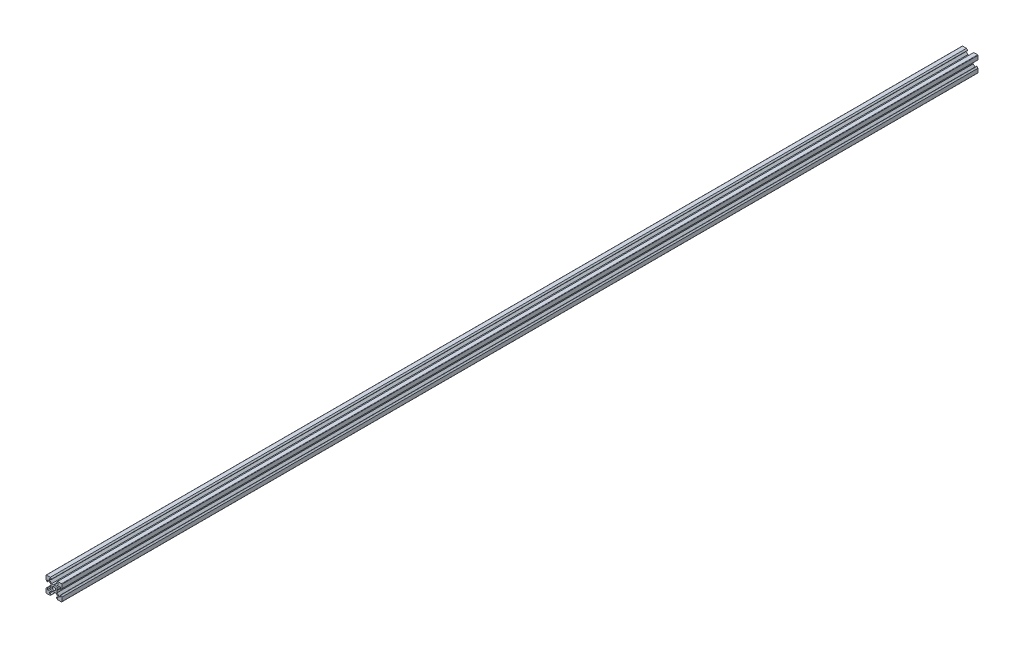
from build123d import *

# Parameters (mm, degrees)
SKETCH1_R           = 2.1
BOSS_EXTRUDE1_DEPTH = 1160


with BuildPart() as part:
    # Sketch1 → Boss-Extrude1 (new body)
    with BuildSketch(Plane.XY):
        with BuildLine():
            Line((4.58, -10), (9.5, -10))
            ThreePointArc((9.5, -10), (9.853553391, -9.853553391), (10, -9.5))
            Line((10, -9.5), (10, -4.58))
            Line((10, -4.58), (8.545, -3.125))
            Line((8.545, -3.125), (8.2, -3.125))
            Line((8.2, -3.125), (8.2, -5.5))
            Line((8.2, -5.5), (6.560660172, -5.5))
            Line((6.560660172, -5.5), (3.9, -2.839339828))
            Line((3.9, -2.839339828), (3.9, -0.21))
            Line((3.9, -0.21), (3.69, 0))
            Line((3.69, 0), (3.9, 0.21))
            Line((3.9, 0.21), (3.9, 2.839339828))
            Line((3.9, 2.839339828), (6.560660172, 5.5))
            Line((6.560660172, 5.5), (8.2, 5.5))
            Line((8.2, 5.5), (8.2, 3.125))
            Line((8.2, 3.125), (8.545, 3.125))
            Line((8.545, 3.125), (10, 4.58))
            Line((10, 4.58), (10, 9.5))
            ThreePointArc((10, 9.5), (9.853553391, 9.853553391), (9.5, 10))
            Line((9.5, 10), (4.58, 10))
            Line((4.58, 10), (3.125, 8.545))
            Line((3.125, 8.545), (3.125, 8.2))
            Line((3.125, 8.2), (5.5, 8.2))
            Line((5.5, 8.2), (5.5, 6.560660172))
            Line((5.5, 6.560660172), (2.839339828, 3.9))
            Line((2.839339828, 3.9), (0.21, 3.9))
            Line((0.21, 3.9), (0, 3.69))
            Line((0, 3.69), (-0.21, 3.9))
            Line((-0.21, 3.9), (-2.839339828, 3.9))
            Line((-2.839339828, 3.9), (-5.5, 6.560660172))
            Line((-5.5, 6.560660172), (-5.5, 8.2))
            Line((-5.5, 8.2), (-3.125, 8.2))
            Line((-3.125, 8.2), (-3.125, 8.545))
            Line((-3.125, 8.545), (-4.58, 10))
            Line((-4.58, 10), (-9.5, 10))
            ThreePointArc((-9.5, 10), (-9.853553391, 9.853553391), (-10, 9.5))
            Line((-10, 9.5), (-10, 4.58))
            Line((-10, 4.58), (-8.545, 3.125))
            Line((-8.545, 3.125), (-8.2, 3.125))
            Line((-8.2, 3.125), (-8.2, 5.5))
            Line((-8.2, 5.5), (-6.560660172, 5.5))
            Line((-6.560660172, 5.5), (-3.9, 2.839339828))
            Line((-3.9, 2.839339828), (-3.9, 0.21))
            Line((-3.9, 0.21), (-3.69, 0))
            Line((-3.69, 0), (-3.9, -0.21))
            Line((-3.9, -0.21), (-3.9, -2.839339828))
            Line((-3.9, -2.839339828), (-6.560660172, -5.5))
            Line((-6.560660172, -5.5), (-8.2, -5.5))
            Line((-8.2, -5.5), (-8.2, -3.125))
            Line((-8.2, -3.125), (-8.545, -3.125))
            Line((-8.545, -3.125), (-10, -4.58))
            Line((-10, -4.58), (-10, -9.5))
            ThreePointArc((-10, -9.5), (-9.853553391, -9.853553391), (-9.5, -10))
            Line((-9.5, -10), (-4.58, -10))
            Line((-4.58, -10), (-3.125, -8.545))
            Line((-3.125, -8.545), (-3.125, -8.2))
            Line((-3.125, -8.2), (-5.5, -8.2))
            Line((-5.5, -8.2), (-5.5, -6.560660172))
            Line((-5.5, -6.560660172), (-2.839339828, -3.9))
            Line((-2.839339828, -3.9), (-0.21, -3.9))
            Line((-0.21, -3.9), (0, -3.69))
            Line((0, -3.69), (0.21, -3.9))
            Line((0.21, -3.9), (2.839339828, -3.9))
            Line((2.839339828, -3.9), (5.5, -6.560660172))
            Line((5.5, -6.560660172), (5.5, -8.2))
            Line((5.5, -8.2), (3.125, -8.2))
            Line((3.125, -8.2), (3.125, -8.545))
            Line((3.125, -8.545), (4.58, -10))
        make_face()
        Circle(SKETCH1_R, mode=Mode.SUBTRACT)
    extrude(amount=BOSS_EXTRUDE1_DEPTH)


solid = part.part
